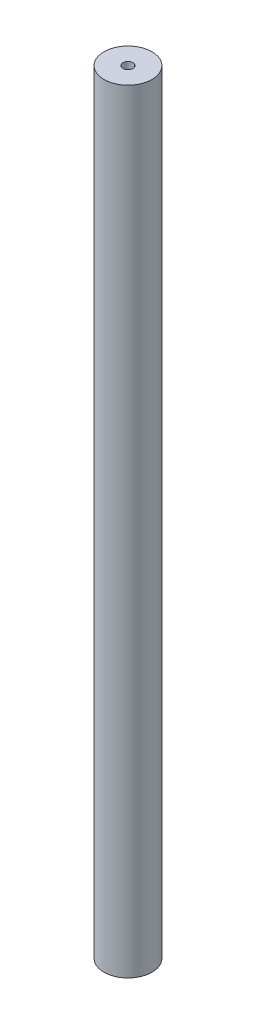
from build123d import *

# Parameters (mm, degrees)
SKETCH1_R           = 10
BOSS_EXTRUDE1_DEPTH = 161.1


with BuildPart() as part:
    # Sketch1 → Boss-Extrude1 (new body, symmetric)
    with BuildSketch(Plane(origin=(0, 0, 0), x_dir=(1, 0, 0), z_dir=(0, 1, 0))):
        Circle(SKETCH1_R)
    extrude(amount=BOSS_EXTRUDE1_DEPTH, both=True)

    # Sketch3 → M5x0.8 Tapped Hole1 (revolve, cut)
    with BuildSketch(Plane(origin=(0, 161.1, 0), x_dir=(0, 0, 1), z_dir=(1, 0, 0))):
        Polygon((0, 0), (0, 23.7618073), (2.1, 22.5), (2.1, 0), align=None)
    m5x0_8_tapped_hole1 = revolve(axis=Axis((0, 167.45, 0), (0, -1, 0)), mode=Mode.SUBTRACT)

    # Mirror1: M5x0.8 Tapped Hole1 across plane
    add(m5x0_8_tapped_hole1.mirror(Plane.ZX), mode=Mode.SUBTRACT)


solid = part.part
